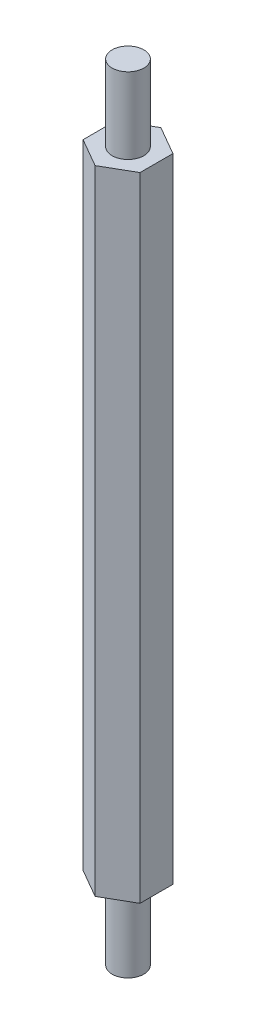
from build123d import *

# Parameters (mm, degrees)
EXTRUDE_1_DEPTH = 25
SKETCH_2_R      = 1.25
EXTRUDE_2_DEPTH = 31


with BuildPart() as part:
    # 草图1 → 凸台-拉伸1 (new body, symmetric)
    with BuildSketch(Plane(origin=(0, 0, 0), x_dir=(1, 0, 0), z_dir=(0, 1, 0))):
        Polygon((2.25, -1.299038106), (2.25, 1.299038106), (0, 2.598076211), (-2.25, 1.299038106), (-2.25, -1.299038106), (0, -2.598076211), align=None)
    extrude(amount=EXTRUDE_1_DEPTH, both=True)

    # 草图2 → 凸台-拉伸2 (add, symmetric)
    with BuildSketch(Plane(origin=(0, 0, 0), x_dir=(1, 0, 0), z_dir=(0, 1, 0))):
        Circle(SKETCH_2_R)
    extrude(amount=EXTRUDE_2_DEPTH, both=True)


solid = part.part
